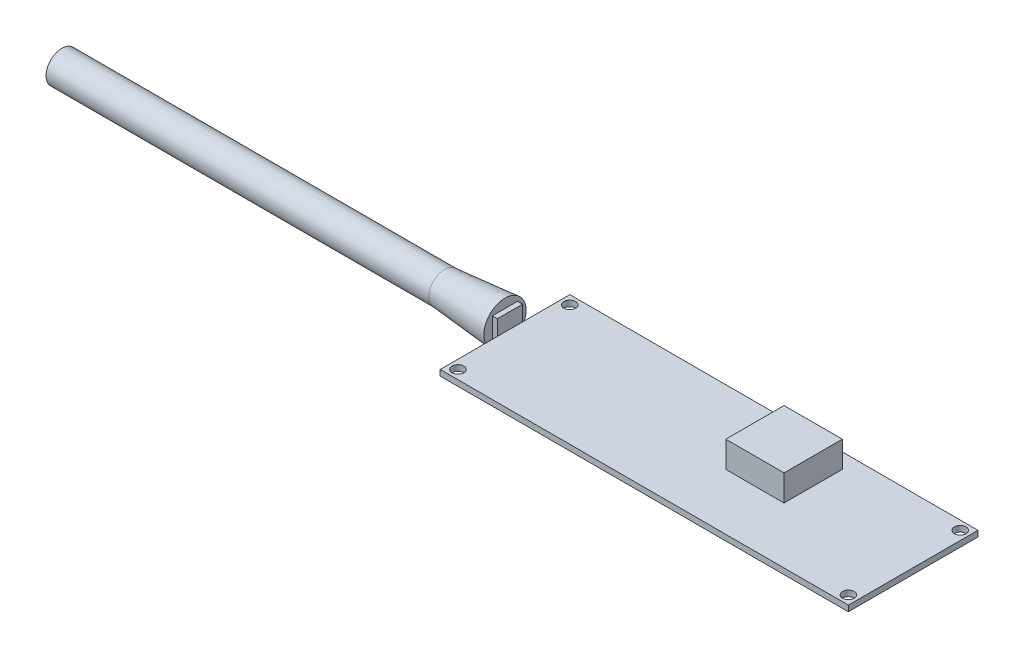
from build123d import *

# Parameters (mm, degrees)
SKETCH1_W             = 103.1748
SKETCH1_H             = 32.766
TRS_PCB_DEPTH         = 1.4605
SKETCH2_R             = 1.4859
STAND_OFF_HOLES_DEPTH = 1.4605
SKETCH3_W             = 14.732
SKETCH3_H             = 14.732
GPS_ANTENNA_DEPTH     = 6.604
SKETCH4_W             = 6.35
SKETCH4_H             = 6.096
BOSS_EXTRUDE2_DEPTH   = 1.27
SKETCH5_R             = 5.334
BOSS_EXTRUDE3_DEPTH   = 15.24
BOSS_EXTRUDE3_TAPER   = 5
SKETCH6_R             = 4.0005
BOSS_EXTRUDE4_DEPTH   = 96.774


with BuildPart() as part:
    # Sketch1 → TRS PCB (new body)
    with BuildSketch(Plane(origin=(0, 0, 0), x_dir=(1, 0, 0), z_dir=(0, 1, 0))):
        Rectangle(SKETCH1_W, SKETCH1_H)
    extrude(amount=TRS_PCB_DEPTH)

    # Sketch2 → Stand off holes (cut)
    with BuildSketch(Plane(origin=(0, 1.4605, 0), x_dir=(1, 0, 0), z_dir=(0, 1, 0))):
        with Locations((-49.3395, 14.1351)):
            Circle(SKETCH2_R)
        with Locations((49.3395, 14.1351)):
            Circle(SKETCH2_R)
        with Locations((49.3395, -14.1351)):
            Circle(SKETCH2_R)
        with Locations((-49.3395, -14.1351)):
            Circle(SKETCH2_R)
    extrude(amount=-STAND_OFF_HOLES_DEPTH, mode=Mode.SUBTRACT)

    # Sketch3 → GPS Antenna (add)
    with BuildSketch(Plane(origin=(0, 1.4605, 0), x_dir=(1, 0, 0), z_dir=(0, 1, 0))):
        with Locations((13.7414, 5.207)):
            Rectangle(SKETCH3_W, SKETCH3_H)
    extrude(amount=GPS_ANTENNA_DEPTH)

    # Sketch4 → Boss-Extrude2 (add)
    with BuildSketch(Plane.ZY.offset(51.5874)):
        with Locations((-1.27, 2.286)):
            Rectangle(SKETCH4_W, SKETCH4_H)
    extrude(amount=BOSS_EXTRUDE2_DEPTH)

    # Sketch5 → Boss-Extrude3 (add)
    with BuildSketch(Plane.ZY.offset(52.8574)):
        with Locations((-1.27, 2.286)):
            Circle(SKETCH5_R)
    extrude(amount=BOSS_EXTRUDE3_DEPTH, taper=BOSS_EXTRUDE3_TAPER)

    # Sketch6 → Boss-Extrude4 (add)
    with BuildSketch(Plane.ZY.offset(68.0974)):
        with Locations((-1.27, 2.286)):
            Circle(SKETCH6_R)
    extrude(amount=BOSS_EXTRUDE4_DEPTH)


solid = part.part
